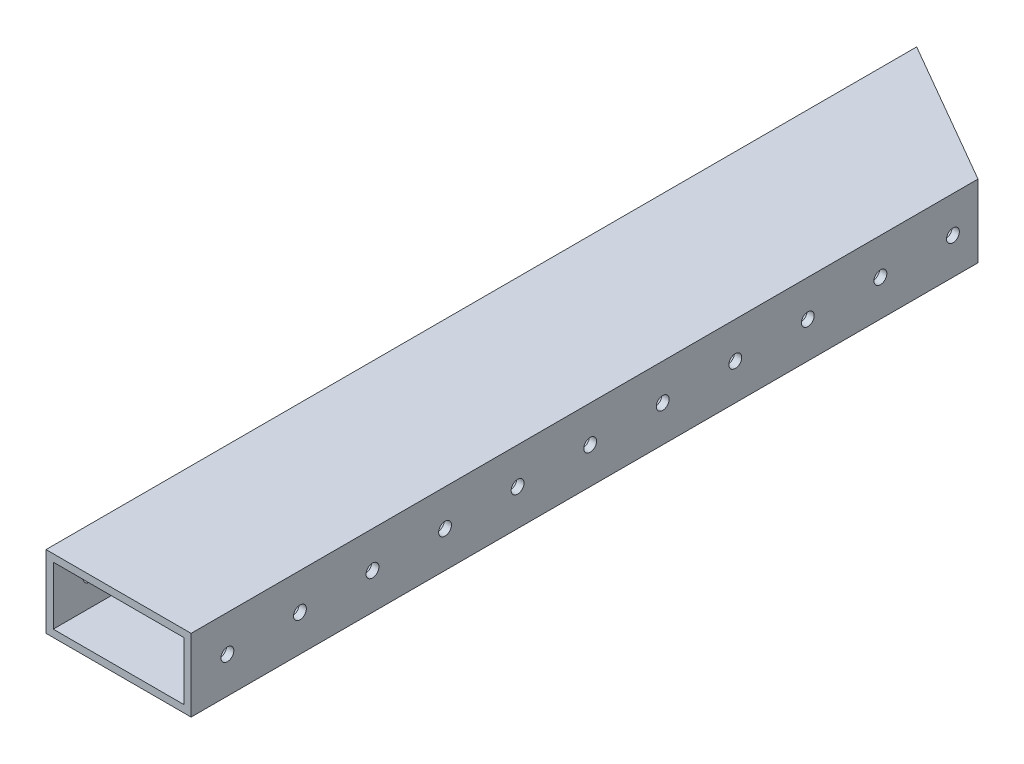
from build123d import *

# Parameters (mm, degrees)
SKETCH1_W             = 50.8
SKETCH1_H             = 25.4
SKETCH1_W_2           = 45.72
SKETCH1_H_2           = 20.32
BOSS_EXTRUDE1_DEPTH   = 533.4
F_8_CLEARANCE_HOLE1_D = 4.4958
CUT_EXTRUDE2_DEPTH    = 76.962
CUT_EXTRUDE4_DEPTH    = 40.64


with BuildPart() as part:
    # Sketch1 → Boss-Extrude1 (new body)
    with BuildSketch(Plane.XY):
        Rectangle(SKETCH1_W, SKETCH1_H)
        Rectangle(SKETCH1_W_2, SKETCH1_H_2, mode=Mode.SUBTRACT)
    extrude(amount=-BOSS_EXTRUDE1_DEPTH)

    # #8 Clearance Hole1 (through all)
    with Locations(Plane(origin=(25.4, 0, 0), x_dir=(0, 0, -1), z_dir=(1, 0, 0))):
        with Locations((12.7, 0), (38.1, 0), (63.5, 0), (88.9, 0), (114.3, 0), (139.7, 0), (165.1, 0), (190.5, 0), (215.9, 0), (241.3, 0), (266.7, 0), (292.1, 0), (317.5, 0), (342.9, 0), (368.3, 0), (393.7, 0), (419.1, 0), (444.5, 0), (469.9, 0), (495.3, 0), (520.7, 0)):
            Hole(F_8_CLEARANCE_HOLE1_D / 2)

    # Sketch4 → Cut-Extrude2 (cut)
    with BuildSketch(Plane(origin=(0, 12.7, 0), x_dir=(1, 0, 0), z_dir=(0, 1, 0))):
        Polygon((-7.206301081, 228.6), (135.513081356, 228.6), (135.513081356, -17.641370014), (-94.056886123, -17.641370014), (-94.056886123, 228.6), align=None)
    extrude(amount=-CUT_EXTRUDE2_DEPTH, mode=Mode.SUBTRACT)

    # Sketch6 → Cut-Extrude4 (cut)
    with BuildSketch(Plane(origin=(0, 12.7, 0), x_dir=(1, 0, 0), z_dir=(0, 1, 0))):
        Polygon((-25.4, 533.4), (25.4, 504.070606325), (25.4, 533.4), align=None)
    extrude(amount=-CUT_EXTRUDE4_DEPTH, mode=Mode.SUBTRACT)


solid = part.part
